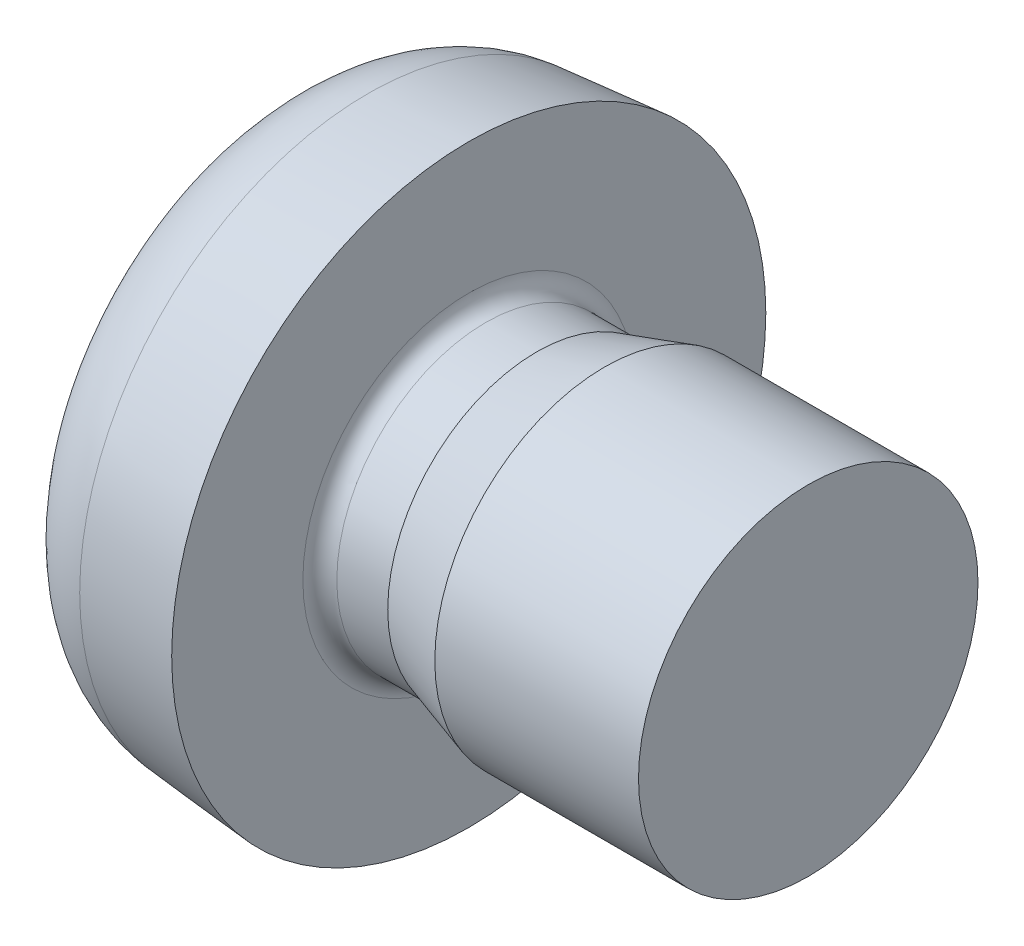
from build123d import *

# Parameters (mm, degrees)
CUT_EXTRUDE_1_DEPTH = 0.65


with BuildPart() as part:
    # ｽｹｯﾁ1 → 回転1 (revolve)
    with BuildSketch(Plane.XY):
        with BuildLine():
            Line((-0.593854493, 1.698044464), (0, 1.75))
            Line((0, 1.75), (0, 0.97725))
            ThreePointArc((0, 0.97725), (0.029289322, 0.906539322), (0.1, 0.87725))
            Line((0.1, 0.87725), (0.4, 0.87725))
            Line((0.4, 0.87725), (0.8, 1))
            Line((0.8, 1), (2, 1))
            Line((2, 1), (2, 0))
            Line((2, 0), (-1.3, 0))
            ThreePointArc((-1.3, 0), (-1.254061978, 0.641351616), (-1.117185824, 1.269608821))
            ThreePointArc((-1.117185824, 1.269608821), (-0.921639459, 1.564590934), (-0.593854493, 1.698044464))
        make_face()
    revolve(axis=Axis((2, 0, 0), (-1, 0, 0)))

    # ｽｹｯﾁ2 → ｶｯﾄ - 押し出し1 (cut)
    with BuildSketch(Plane(origin=(-1.3, 0, 0), x_dir=(0, 0, -1), z_dir=(1, 0, 0))):
        with BuildLine():
            Line((-1.1, 0.233333333), (-1.1, -0.233333333))
            Line((-1.1, -0.233333333), (-0.583333333, -0.233333333))
            ThreePointArc((-0.583333333, -0.233333333), (-0.33584596, -0.33584596), (-0.233333333, -0.583333333))
            Line((-0.233333333, -0.583333333), (-0.233333333, -1.1))
            Line((-0.233333333, -1.1), (0.233333333, -1.1))
            Line((0.233333333, -1.1), (0.233333333, -0.583333333))
            ThreePointArc((0.233333333, -0.583333333), (0.33584596, -0.33584596), (0.583333333, -0.233333333))
            Line((0.583333333, -0.233333333), (1.1, -0.233333333))
            Line((1.1, -0.233333333), (1.1, 0.233333333))
            Line((1.1, 0.233333333), (0.583333333, 0.233333333))
            ThreePointArc((0.583333333, 0.233333333), (0.33584596, 0.33584596), (0.233333333, 0.583333333))
            Line((0.233333333, 0.583333333), (0.233333333, 1.1))
            Line((0.233333333, 1.1), (-0.233333333, 1.1))
            Line((-0.233333333, 1.1), (-0.233333333, 0.583333333))
            ThreePointArc((-0.233333333, 0.583333333), (-0.33584596, 0.33584596), (-0.583333333, 0.233333333))
            Line((-0.583333333, 0.233333333), (-1.1, 0.233333333))
        make_face()
    extrude(amount=CUT_EXTRUDE_1_DEPTH, mode=Mode.SUBTRACT)


solid = part.part
